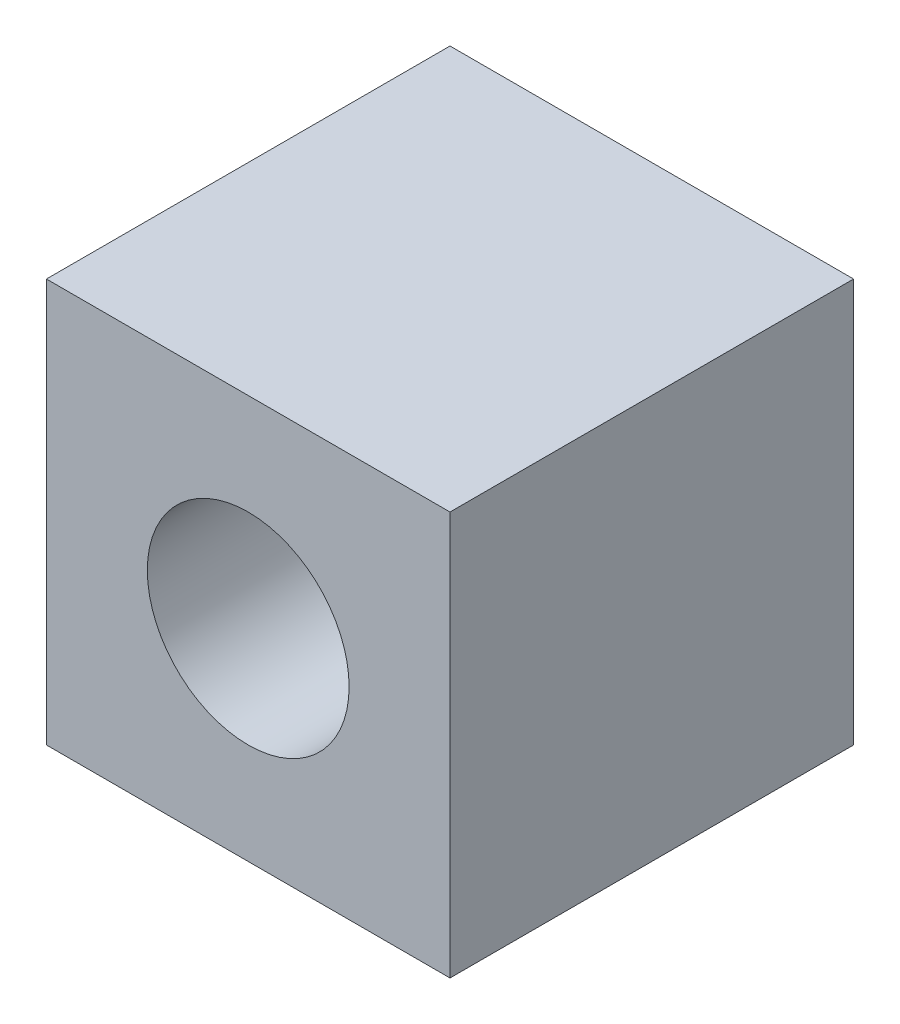
from build123d import *

# Parameters (mm, degrees)
SKETCH1_W           = 10
SKETCH1_H           = 10
SKETCH1_R           = 2.5
BOSS_EXTRUDE1_DEPTH = 10


with BuildPart() as part:
    # Sketch1 → Boss-Extrude1 (new body)
    with BuildSketch(Plane.XY):
        Rectangle(SKETCH1_W, SKETCH1_H)
        Circle(SKETCH1_R, mode=Mode.SUBTRACT)
    extrude(amount=BOSS_EXTRUDE1_DEPTH)


solid = part.part
